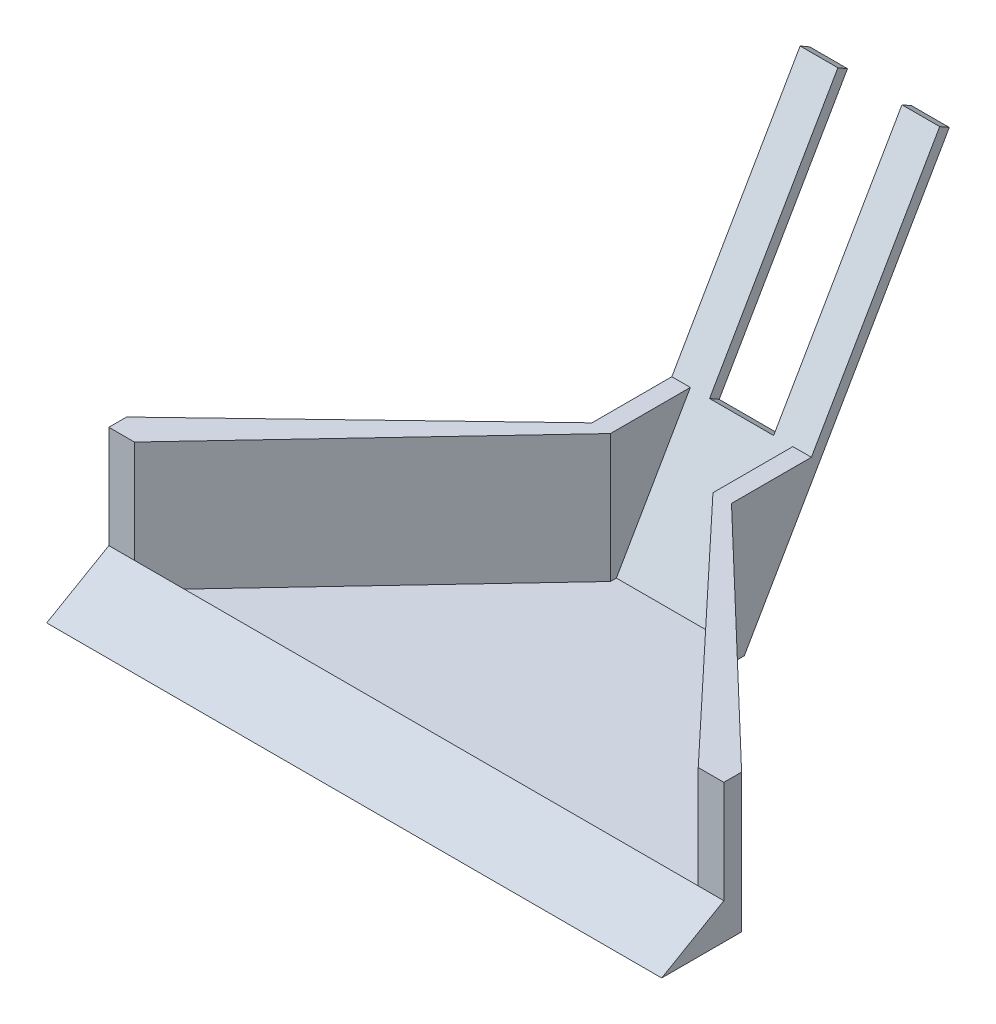
from build123d import *

# Parameters (mm, degrees)
SKETCH2_W           = 304.8
SKETCH2_H           = 17.78
BOSS_EXTRUDE1_DEPTH = 152.4
SKETCH3_W           = 121.604136641
SKETCH3_H           = 12.7
CUT_EXTRUDE1_DEPTH  = 305.8
CUT_EXTRUDE2_DEPTH  = 203.2
BOSS_EXTRUDE6_DEPTH = 63.5
BOSS_EXTRUDE8_DEPTH = 76.2
BOSS_EXTRUDE9_DEPTH = 69.163311
CUT_EXTRUDE4_REACH  = 230.6
SKETCH14_W          = 31.75
SKETCH14_H          = 203.2
CUT_EXTRUDE5_DEPTH  = 116.484487595
SKETCH15_W          = 69.163311332
SKETCH15_H          = 50.8
CUT_EXTRUDE6_DEPTH  = 12.7


with BuildPart() as part:
    # Sketch2 → Boss-Extrude1 (new body)
    with BuildSketch(Plane.XY):
        with Locations((152.4, 8.89)):
            Rectangle(SKETCH2_W, SKETCH2_H)
    extrude(amount=BOSS_EXTRUDE1_DEPTH)

    # Sketch3 → Cut-Extrude1 (cut, through all)
    with BuildSketch(Plane(origin=(304.8, 0, 0), x_dir=(0, 0, -1), z_dir=(1, 0, 0))):
        Polygon((-152.4, 17.78), (-152.4, 0), (-121.604136641, 17.78), align=None)
        with Locations((-60.802068321, 11.43)):
            Rectangle(SKETCH3_W, SKETCH3_H)
    extrude(amount=-CUT_EXTRUDE1_DEPTH, mode=Mode.SUBTRACT)

    # Sketch4 → Cut-Extrude2 (cut)
    with BuildSketch(Plane(origin=(0, 5.08, 0), x_dir=(1, 0, 0), z_dir=(0, 1, 0))):
        Polygon((0, 0), (0, -112.812583018), (117.818344334, 0), align=None)
        Polygon((304.8, 0), (186.981655666, 0), (304.8, -112.812583018), align=None)
    extrude(amount=-CUT_EXTRUDE2_DEPTH, mode=Mode.SUBTRACT)

    # Sketch5 → Boss-Extrude6 (add)
    with BuildSketch(Plane(origin=(0, 5.08, 0), x_dir=(1, 0, 0), z_dir=(0, 1, 0))):
        Polygon((127, 0), (117.818344334, 0), (0, -112.812583018), (0, -121.604136641), (12.7, -121.604136641), align=None)
        Polygon((177.8, 0), (186.981655666, 0), (304.8, -112.812583018), (304.8, -121.604136641), (292.1, -121.604136641), align=None)
    extrude(amount=BOSS_EXTRUDE6_DEPTH)

    # Sketch8 → Boss-Extrude8 (add)
    with BuildSketch(Plane(origin=(0, 0, 0), x_dir=(-1, 0, 0), z_dir=(0, 0, -1))):
        Polygon((-186.981655666, 68.58), (-186.981655666, 0), (-117.818344334, 0), (-117.818344334, 68.58), (-127, 68.58), (-127, 5.08), (-177.8, 5.08), (-177.8, 68.58), align=None)
    extrude(amount=BOSS_EXTRUDE8_DEPTH)

    # Sketch10 → Boss-Extrude9 (add)
    with BuildSketch(Plane(origin=(186.981655666, 0, 0), x_dir=(0, 0, -1), z_dir=(1, 0, 0))):
        Polygon((6.35, 0), (0, 0), (127, 219.970452561), (133.35, 219.970452561), align=None)
    extrude(amount=-BOSS_EXTRUDE9_DEPTH)

    # Cut-Extrude4: up to this face of the body (flat: up to its plane)
    cut_extrude4_end = Plane(part.part.faces().sort_by_distance((152.400000127, 118.969659324, -75.037164836))[0])
    # Sketch12 → Cut-Extrude4 (cut, up to the picked face)
    with BuildSketch(Plane(origin=(0, 0, -76.2), x_dir=(-1, 0, 0), z_dir=(0, 0, -1)), mode=Mode.PRIVATE) as cut_extrude4_sk1:
        Polygon((-186.981655666, 0), (-186.981655666, 68.58), (-177.8, 68.58), (-177.8, 5.08), (-127, 5.08), (-127, 68.58), (-117.818344334, 68.58), (-117.818344334, 0), align=None)
    cut_extrude4_tool1 = split(extrude(cut_extrude4_sk1.sketch, amount=-CUT_EXTRUDE4_REACH, mode=Mode.PRIVATE), bisect_by=cut_extrude4_end, keep=Keep.BOTH, mode=Mode.PRIVATE)
    add(cut_extrude4_tool1.solids().sort_by_distance((186.007655, 34.29, -76.2))[0], mode=Mode.SUBTRACT)

    # Sketch14 → Cut-Extrude5 (cut, through all)
    with BuildSketch(Plane(origin=(0, 0, 0), x_dir=(1, 0, 0), z_dir=(0, 0.5, 0.866025404))):
        with Locations((152.4, 180.789362922)):
            Rectangle(SKETCH14_W, SKETCH14_H)
    extrude(amount=-CUT_EXTRUDE5_DEPTH, mode=Mode.SUBTRACT)

    # Sketch15 → Cut-Extrude6 (cut)
    with BuildSketch(Plane(origin=(0, 0, 0), x_dir=(1, 0, 0), z_dir=(0, 0.5, 0.866025404))):
        with Locations((152.4, 231.775)):
            Rectangle(SKETCH15_W, SKETCH15_H)
    extrude(amount=-CUT_EXTRUDE6_DEPTH, mode=Mode.SUBTRACT)


solid = part.part
